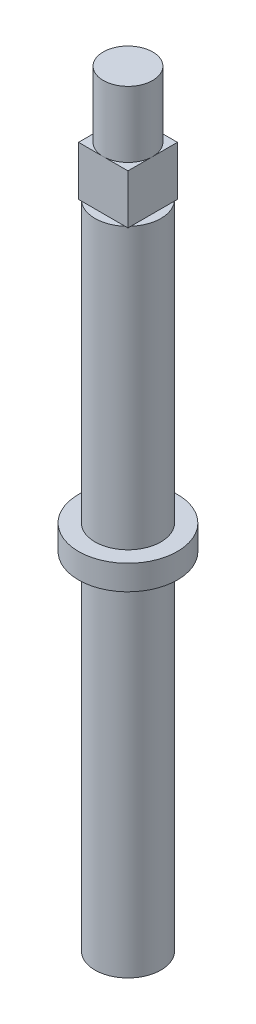
from build123d import *

# Parameters (mm, degrees)
SKETCH2_W           = 6
SKETCH2_H           = 6
BOSS_EXTRUDE1_DEPTH = 6


with BuildPart() as part:
    # Sketch1 → Revolve1 (revolve)
    with BuildSketch(Plane(origin=(0, 0, 0), x_dir=(0, 0, -1), z_dir=(1, 0, 0))):
        Polygon((0, 46.5), (3, 46.5), (3, 32.5), (4, 32.5), (4, -1.5), (6, -1.5), (6, -4.5), (4, -4.5), (4, -46.5), (0, -46.5), align=None)
    revolve(axis=Axis((0, 46.5, 0), (0, -1, 0)))

    # Sketch2 → Boss-Extrude1 (add)
    with BuildSketch(Plane(origin=(0, 32.5, 0), x_dir=(1, 0, 0), z_dir=(0, 1, 0))):
        Rectangle(SKETCH2_W, SKETCH2_H)
    extrude(amount=BOSS_EXTRUDE1_DEPTH)


solid = part.part
